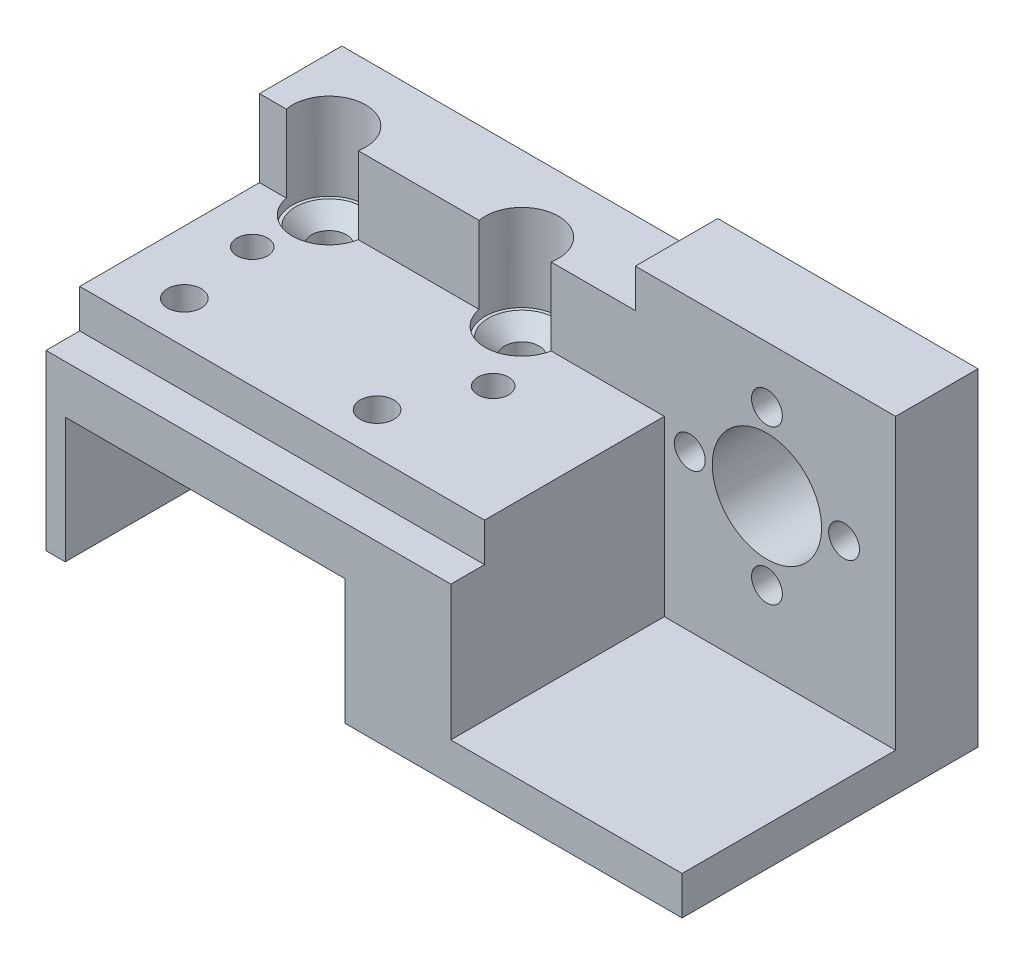
from build123d import *

# Parameters (mm, degrees)
CROQUIS2_R                                           = 10.875
CROQUIS2_R_2                                         = 5.67
CROQUIS2_R_3                                         = 1.6
SALIENTE_EXTRUIR1_DEPTH                              = 30.7
CROQUIS4_W                                           = 24
CROQUIS4_H                                           = 30
CROQUIS4_R                                           = 1.6
CROQUIS4_R_2                                         = 5.67
CORTAR_EXTRUIR2_DEPTH                                = 22.7
CROQUIS3_W                                           = 12.3
CROQUIS3_H                                           = 8
CORTAR_EXTRUIR5_DEPTH                                = 42
CROQUIS5_R                                           = 1.6
CORTAR_EXTRUIR6_DEPTH                                = 35
CROQUIS7_R                                           = 1.6
CORTAR_EXTRUIR7_DEPTH                                = 4
CROQUIS9_W                                           = 8
CROQUIS9_H                                           = 4
SALIENTE_EXTRUIR4_DEPTH                              = 3
CROQUIS7_3_W                                         = 42
CROQUIS7_3_H                                         = 9.85
CORTAR_EXTRUIR8_DEPTH                                = 12
CORTAR_EXTRUIR9_START                                = 8
CORTAR_EXTRUIR9_DEPTH                                = 9
CROQUIS11_3_R                                        = 1.75
CORTAR_EXTRUIR10_DEPTH                               = 23
CORTAR_EXTRUIR11_START                               = -9
CORTAR_EXTRUIR11_DEPTH                               = 4
CORTAR_EXTRUIR11_DEPTH_BACK                          = 23
AVELLANADO_PARA_TORNILLO_CON_CABEZA_AVEL_D           = 3.6
AVELLANADO_PARA_TORNILLO_CON_CABEZA_AVEL_CSINK_D     = 6.94
AVELLANADO_PARA_TORNILLO_CON_CABEZA_AVEL_CSINK_ANGLE = 90
CROQUIS18_W                                          = 42
CROQUIS18_H                                          = 3.5
CORTAR_EXTRUIR12_DEPTH                               = 4
CROQUIS19_R                                          = 5.67
CROQUIS19_R_2                                        = 1.6
SALIENTE_EXTRUIR5_DEPTH                              = 0.55


with BuildPart() as part:
    # Croquis2 → Saliente-Extruir1 (new body)
    with BuildSketch(Plane.XY):
        Polygon((-52.65, 13.85), (-52.65, -20.15), (-50.65, -20.15), (-50.65, -17.65), (-50.65, -7.65), (-50.65, -7.15), (-49.65, -7.15), (-22.65, -7.15), (-21.65, -7.15), (-21.65, -7.65), (-21.65, -17.65), (-21.65, -20.15), (13.35, -20.15), (13.35, 13.85), align=None)
        Circle(CROQUIS2_R, mode=Mode.SUBTRACT)
        Circle(CROQUIS2_R)
        Circle(CROQUIS2_R_2, mode=Mode.SUBTRACT)
        with Locations((0, -8)):
            Circle(CROQUIS2_R_3, mode=Mode.SUBTRACT)
        with Locations((-8, 0)):
            Circle(CROQUIS2_R_3, mode=Mode.SUBTRACT)
        with Locations((8, 0)):
            Circle(CROQUIS2_R_3, mode=Mode.SUBTRACT)
        with Locations((0, 8)):
            Circle(CROQUIS2_R_3, mode=Mode.SUBTRACT)
    extrude(amount=SALIENTE_EXTRUIR1_DEPTH)

    # Croquis4 → Cortar-Extruir2 (cut)
    with BuildSketch(Plane.XY.offset(30.7)):
        with Locations((1.35, -1.15)):
            Rectangle(CROQUIS4_W, CROQUIS4_H)
        with Locations((0, -8)):
            Circle(CROQUIS4_R, mode=Mode.SUBTRACT)
        with Locations((-8, 0)):
            Circle(CROQUIS4_R, mode=Mode.SUBTRACT)
        Circle(CROQUIS4_R_2, mode=Mode.SUBTRACT)
        with Locations((0, 8)):
            Circle(CROQUIS4_R, mode=Mode.SUBTRACT)
        with Locations((8, 0)):
            Circle(CROQUIS4_R, mode=Mode.SUBTRACT)
    extrude(amount=-CORTAR_EXTRUIR2_DEPTH, mode=Mode.SUBTRACT)

    # Croquis3 → Cortar-Extruir5 (cut)
    with BuildSketch(Plane.ZY.offset(52.65)):
        with Locations((14.7, 5.85)):
            Rectangle(CROQUIS3_W, CROQUIS3_H)
    extrude(amount=-CORTAR_EXTRUIR5_DEPTH, mode=Mode.SUBTRACT)

    # Croquis5 → Cortar-Extruir6 (cut, through all)
    with BuildSketch(Plane(origin=(0, 13.85, 0), x_dir=(1, 0, 0), z_dir=(0, 1, 0))):
        with Locations((-47.25, -14.7)):
            Circle(CROQUIS5_R)
        with Locations((-22.25, -14.7)):
            Circle(CROQUIS5_R)
    extrude(amount=-CORTAR_EXTRUIR6_DEPTH, mode=Mode.SUBTRACT)

    # Croquis7 → Cortar-Extruir7 (cut)
    with BuildSketch(Plane(origin=(0, 13.85, 0), x_dir=(1, 0, 0), z_dir=(0, 1, 0))):
        Polygon((-52.65, -8.55), (-52.65, -20.85), (-10.65, -20.85), (-10.65, 0), (-52.65, 0), align=None)
        with Locations((-47.25, -14.7)):
            Circle(CROQUIS7_R, mode=Mode.SUBTRACT)
        with Locations((-22.25, -14.7)):
            Circle(CROQUIS7_R, mode=Mode.SUBTRACT)
    extrude(amount=-CORTAR_EXTRUIR7_DEPTH, mode=Mode.SUBTRACT)

    # Croquis9 → Saliente-Extruir4 (add)
    with BuildSketch(Plane.ZY.offset(10.65)):
        with Locations((4, 11.85)):
            Rectangle(CROQUIS9_W, CROQUIS9_H)
    extrude(amount=SALIENTE_EXTRUIR4_DEPTH)

    # Croquis7_3 → Cortar-Extruir8 (cut)
    with BuildSketch(Plane(origin=(0, 13.85, 0), x_dir=(1, 0, 0), z_dir=(0, 1, 0))):
        with Locations((-31.65, -25.775)):
            Rectangle(CROQUIS7_3_W, CROQUIS7_3_H)
    extrude(amount=-CORTAR_EXTRUIR8_DEPTH, mode=Mode.SUBTRACT)

    # Croquis11 → Cortar-Extruir9 (cut)
    with BuildSketch(Plane(origin=(0, 1.85, 0), x_dir=(1, 0, 0), z_dir=(0, 1, 0)).offset(CORTAR_EXTRUIR9_START)):
        with BuildLine():
            ThreePointArc((-42.32985075, -7.85), (-46.481357833, -4.066292457), (-49.86482063, -8.55))
            Line((-49.86482063, -8.55), (-47.733752244, -8.55))
            ThreePointArc((-47.733752244, -8.55), (-46.487392627, -6.136913952), (-44.37985075, -7.85))
            ThreePointArc((-44.37985075, -7.85), (-44.416764703, -8.207541876), (-44.525949257, -8.55))
            Line((-44.525949257, -8.55), (-42.394880871, -8.55))
            ThreePointArc((-42.394880871, -8.55), (-42.346143207, -8.201507083), (-42.32985075, -7.85))
        make_face()
        with BuildLine():
            Line((-48.33977205, -10.941318141), (-47.25, -10.312137954))
            Line((-47.25, -10.312137954), (-45.153646097, -11.522468444))
            ThreePointArc((-45.153646097, -11.522468444), (-43.344588908, -10.435017692), (-42.394880871, -8.55))
            Line((-42.394880871, -8.55), (-44.525949257, -8.55))
            ThreePointArc((-44.525949257, -8.55), (-46.12985075, -9.6), (-47.733752244, -8.55))
            Line((-47.733752244, -8.55), (-49.86482063, -8.55))
            ThreePointArc((-49.86482063, -8.55), (-49.333759831, -9.893273502), (-48.33977205, -10.941318141))
        make_face()
        with BuildLine():
            Line((-45.153646097, -11.522468444), (-47.25, -10.312137954))
            Line((-47.25, -10.312137954), (-48.33977205, -10.941318141))
            ThreePointArc((-48.33977205, -10.941318141), (-46.811721787, -11.588322069), (-45.153646097, -11.522468444))
        make_face()
        with BuildLine():
            Line((-44.525949257, -8.55), (-47.733752244, -8.55))
            ThreePointArc((-47.733752244, -8.55), (-46.12985075, -9.6), (-44.525949257, -8.55))
        make_face()
        with BuildLine():
            ThreePointArc((-44.37985075, -7.85), (-46.487392627, -6.136913952), (-47.733752244, -8.55))
            Line((-47.733752244, -8.55), (-44.525949257, -8.55))
            ThreePointArc((-44.525949257, -8.55), (-44.416764703, -8.207541876), (-44.37985075, -7.85))
        make_face()
        with BuildLine():
            ThreePointArc((-22.32985075, -7.85), (-26.481357833, -4.066292457), (-29.86482063, -8.55))
            Line((-29.86482063, -8.55), (-27.733752244, -8.55))
            ThreePointArc((-27.733752244, -8.55), (-26.487392627, -6.136913952), (-24.37985075, -7.85))
            ThreePointArc((-24.37985075, -7.85), (-24.416764703, -8.207541876), (-24.525949257, -8.55))
            Line((-24.525949257, -8.55), (-22.394880871, -8.55))
            ThreePointArc((-22.394880871, -8.55), (-22.346143207, -8.201507083), (-22.32985075, -7.85))
        make_face()
        with BuildLine():
            Line((-27.733752244, -8.55), (-29.86482063, -8.55))
            ThreePointArc((-29.86482063, -8.55), (-26.12985075, -11.65), (-22.394880871, -8.55))
            Line((-22.394880871, -8.55), (-24.525949257, -8.55))
            ThreePointArc((-24.525949257, -8.55), (-26.12985075, -9.6), (-27.733752244, -8.55))
        make_face()
        with BuildLine():
            Line((-24.525949257, -8.55), (-27.733752244, -8.55))
            ThreePointArc((-27.733752244, -8.55), (-26.12985075, -9.6), (-24.525949257, -8.55))
        make_face()
        with BuildLine():
            ThreePointArc((-24.37985075, -7.85), (-26.487392627, -6.136913952), (-27.733752244, -8.55))
            Line((-27.733752244, -8.55), (-24.525949257, -8.55))
            ThreePointArc((-24.525949257, -8.55), (-24.416764703, -8.207541876), (-24.37985075, -7.85))
        make_face()
    extrude(amount=-CORTAR_EXTRUIR9_DEPTH, mode=Mode.SUBTRACT)

    # Croquis11_3 → Cortar-Extruir10 (cut, through all)
    with BuildSketch(Plane(origin=(0, 1.85, 0), x_dir=(1, 0, 0), z_dir=(0, 1, 0))):
        with BuildLine():
            Line((-44.525949257, -8.55), (-47.733752244, -8.55))
            ThreePointArc((-47.733752244, -8.55), (-46.12985075, -9.6), (-44.525949257, -8.55))
        make_face()
        with BuildLine():
            ThreePointArc((-44.37985075, -7.85), (-46.487392627, -6.136913952), (-47.733752244, -8.55))
            Line((-47.733752244, -8.55), (-44.525949257, -8.55))
            ThreePointArc((-44.525949257, -8.55), (-44.416764703, -8.207541876), (-44.37985075, -7.85))
        make_face()
        with BuildLine():
            Line((-24.525949257, -8.55), (-27.733752244, -8.55))
            ThreePointArc((-27.733752244, -8.55), (-26.12985075, -9.6), (-24.525949257, -8.55))
        make_face()
        with BuildLine():
            ThreePointArc((-24.37985075, -7.85), (-26.487392627, -6.136913952), (-27.733752244, -8.55))
            Line((-27.733752244, -8.55), (-24.525949257, -8.55))
            ThreePointArc((-24.525949257, -8.55), (-24.416764703, -8.207541876), (-24.37985075, -7.85))
        make_face()
        with Locations((-26.15, -22.849986467)):
            Circle(CROQUIS11_3_R)
        with Locations((-46.15, -22.849986467)):
            Circle(CROQUIS11_3_R)
    extrude(amount=-CORTAR_EXTRUIR10_DEPTH, mode=Mode.SUBTRACT)

    # Croquis11_4 → Cortar-Extruir11 (cut, two sides)
    with BuildSketch(Plane(origin=(0, 1.85, 0), x_dir=(1, 0, 0), z_dir=(0, 1, 0)).offset(CORTAR_EXTRUIR11_START)) as cortar_extruir11_sk:
        Polygon((-47.25, -10.312137954), (-51.05, -12.506068977), (-51.05, -16.893931023), (-47.25, -19.087862046), (-43.45, -16.893931023), (-43.45, -12.506068977), align=None)
        Polygon((-22.25, -10.312137954), (-26.05, -12.506068977), (-26.05, -16.893931023), (-22.25, -19.087862046), (-18.45, -16.893931023), (-18.45, -12.506068977), align=None)
    extrude(amount=CORTAR_EXTRUIR11_DEPTH, mode=Mode.SUBTRACT)
    extrude(cortar_extruir11_sk.sketch, amount=-CORTAR_EXTRUIR11_DEPTH_BACK, mode=Mode.SUBTRACT)

    # Avellanado para tornillo con cabeza avel (through all)
    with Locations(Plane(origin=(0, 0.85, 0), x_dir=(1, 0, 0), z_dir=(0, 1, 0))):
        with Locations((-46.12985075, -7.85), (-26.12985075, -7.85)):
            CounterSinkHole(AVELLANADO_PARA_TORNILLO_CON_CABEZA_AVEL_D / 2, AVELLANADO_PARA_TORNILLO_CON_CABEZA_AVEL_CSINK_D / 2, counter_sink_angle=AVELLANADO_PARA_TORNILLO_CON_CABEZA_AVEL_CSINK_ANGLE)

    # Croquis18 → Cortar-Extruir12 (cut)
    with BuildSketch(Plane(origin=(0, 1.85, 0), x_dir=(1, 0, 0), z_dir=(0, 1, 0))):
        with Locations((-31.65, -28.95)):
            Rectangle(CROQUIS18_W, CROQUIS18_H)
    extrude(amount=-CORTAR_EXTRUIR12_DEPTH, mode=Mode.SUBTRACT)

    # Croquis19 → Saliente-Extruir5 (add)
    with BuildSketch(Plane.XY.offset(8)):
        Polygon((-10.65, 9.85), (-10.65, -16.15), (13.35, -16.15), (13.35, 13.85), (-13.65, 13.85), (-13.65, 9.85), align=None)
        Circle(CROQUIS19_R, mode=Mode.SUBTRACT)
        with Locations((0, -8)):
            Circle(CROQUIS19_R_2, mode=Mode.SUBTRACT)
        with Locations((8, 0)):
            Circle(CROQUIS19_R_2, mode=Mode.SUBTRACT)
        with Locations((0, 8)):
            Circle(CROQUIS19_R_2, mode=Mode.SUBTRACT)
        with Locations((-8, 0)):
            Circle(CROQUIS19_R_2, mode=Mode.SUBTRACT)
    extrude(amount=SALIENTE_EXTRUIR5_DEPTH)


solid = part.part
